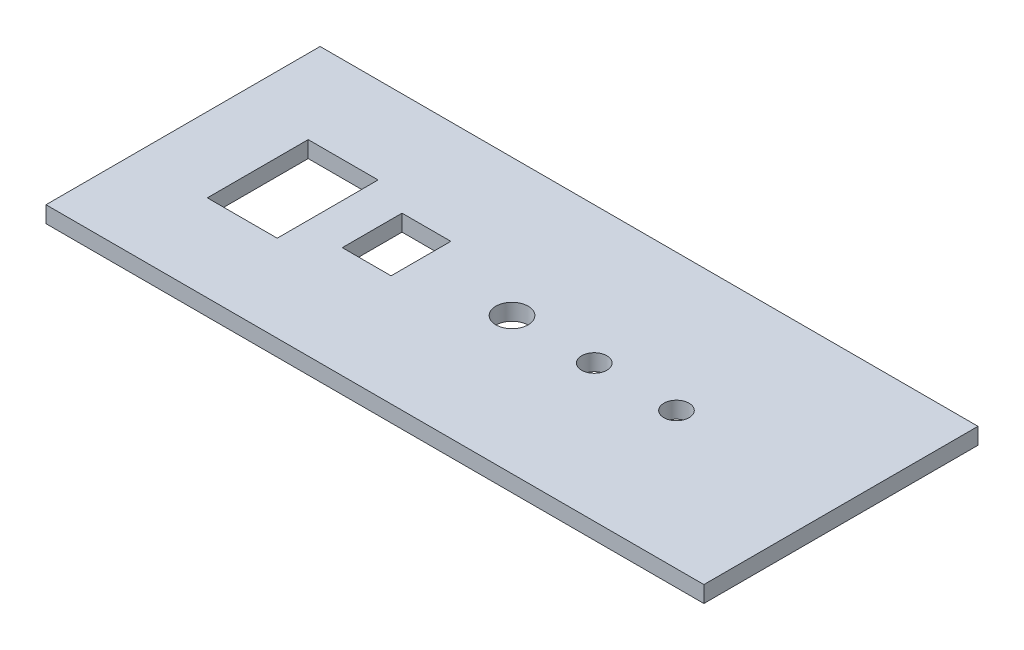
from build123d import *

# Parameters (mm, degrees)
SKETCH1_W           = 120
SKETCH1_H           = 50
BOSS_EXTRUDE1_DEPTH = 3
SKETCH2_R           = 2.95
SKETCH2_R_2         = 2.3
SKETCH2_W           = 12.75
SKETCH2_H           = 18.4
CUT_EXTRUDE1_DEPTH  = 3
SKETCH3_W           = 8.9
SKETCH3_H           = 10.9
CUT_EXTRUDE2_DEPTH  = 10


with BuildPart() as part:
    # Sketch1 → Boss-Extrude1 (new body)
    with BuildSketch(Plane(origin=(0, 0, 0), x_dir=(1, 0, 0), z_dir=(0, 1, 0))):
        with Locations((-60, 25)):
            Rectangle(SKETCH1_W, SKETCH1_H)
    extrude(amount=BOSS_EXTRUDE1_DEPTH)

    # Sketch2 → Cut-Extrude1 (cut)
    with BuildSketch(Plane(origin=(0, 3, 0), x_dir=(1, 0, 0), z_dir=(0, 1, 0))):
        with Locations(Location((-60, 25, 0), (0, 0, 270))):  # turned: the seam where the file's is
            Circle(SKETCH2_R)
        with Locations(Location((-45, 25, 0), (0, 0, 270))):  # turned: the seam where the file's is
            Circle(SKETCH2_R_2)
        with Locations(Location((-30, 25, 0), (0, 0, 270))):  # turned: the seam where the file's is
            Circle(SKETCH2_R_2)
        with Locations((-100, 25)):
            Rectangle(SKETCH2_W, SKETCH2_H)
    extrude(amount=-CUT_EXTRUDE1_DEPTH, mode=Mode.SUBTRACT)

    # Sketch3 → Cut-Extrude2 (cut)
    with BuildSketch(Plane(origin=(0, 3, 0), x_dir=(1, 0, 0), z_dir=(0, 1, 0))):
        with Locations((-81.74741462, 25.690314881)):
            Rectangle(SKETCH3_W, SKETCH3_H)
    extrude(amount=-CUT_EXTRUDE2_DEPTH, mode=Mode.SUBTRACT)


solid = part.part
